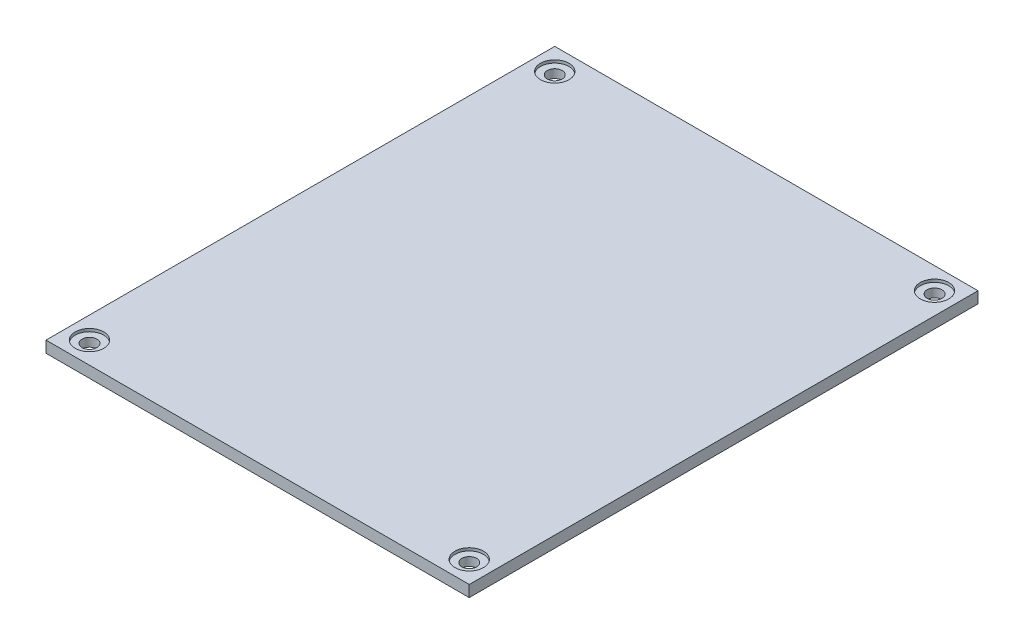
from build123d import *

# Parameters (mm, degrees)
SKETCH1_W           = 74.168
SKETCH1_H           = 89.154
SKETCH1_R           = 2.5
BOSS_EXTRUDE2_DEPTH = 2
SKETCH1_3_R         = 2.5
SKETCH1_3_R_2       = 1.3
BOSS_EXTRUDE3_DEPTH = 1.5


with BuildPart() as part:
    # Sketch1 → Boss-Extrude2 (new body)
    with BuildSketch(Plane(origin=(0, 0, 0), x_dir=(1, 0, 0), z_dir=(0, 1, 0))):
        Rectangle(SKETCH1_W, SKETCH1_H)
        with Locations((-33.274, -40.767)):
            Circle(SKETCH1_R, mode=Mode.SUBTRACT)
        with Locations((33.274, -40.767)):
            Circle(SKETCH1_R, mode=Mode.SUBTRACT)
        with Locations((-33.274, 40.767)):
            Circle(SKETCH1_R, mode=Mode.SUBTRACT)
        with Locations((33.274, 40.767)):
            Circle(SKETCH1_R, mode=Mode.SUBTRACT)
    extrude(amount=BOSS_EXTRUDE2_DEPTH)

    # Sketch1_3 → Boss-Extrude3 (add)
    # profile 1 of 4: a face of its own
    with BuildSketch(Plane(origin=(0, 0, 0), x_dir=(1, 0, 0), z_dir=(0, 1, 0))):
        with Locations((-33.274, 40.767)):
            Circle(SKETCH1_3_R)
        with Locations((-33.274, 40.767)):
            Circle(SKETCH1_3_R_2, mode=Mode.SUBTRACT)
    # profile 2 of 4: a face of its own
    with BuildSketch(Plane(origin=(0, 0, 0), x_dir=(1, 0, 0), z_dir=(0, 1, 0))):
        with Locations((33.274, 40.767)):
            Circle(SKETCH1_3_R)
        with Locations((33.274, 40.767)):
            Circle(SKETCH1_3_R_2, mode=Mode.SUBTRACT)
    # profile 3 of 4: a face of its own
    with BuildSketch(Plane(origin=(0, 0, 0), x_dir=(1, 0, 0), z_dir=(0, 1, 0))):
        with Locations((33.274, -40.767)):
            Circle(SKETCH1_3_R)
        with Locations((33.274, -40.767)):
            Circle(SKETCH1_3_R_2, mode=Mode.SUBTRACT)
    # profile 4 of 4: a face of its own
    with BuildSketch(Plane(origin=(0, 0, 0), x_dir=(1, 0, 0), z_dir=(0, 1, 0))):
        with Locations((-33.274, -40.767)):
            Circle(SKETCH1_3_R)
        with Locations((-33.274, -40.767)):
            Circle(SKETCH1_3_R_2, mode=Mode.SUBTRACT)
    extrude(amount=BOSS_EXTRUDE3_DEPTH)


solid = part.part
